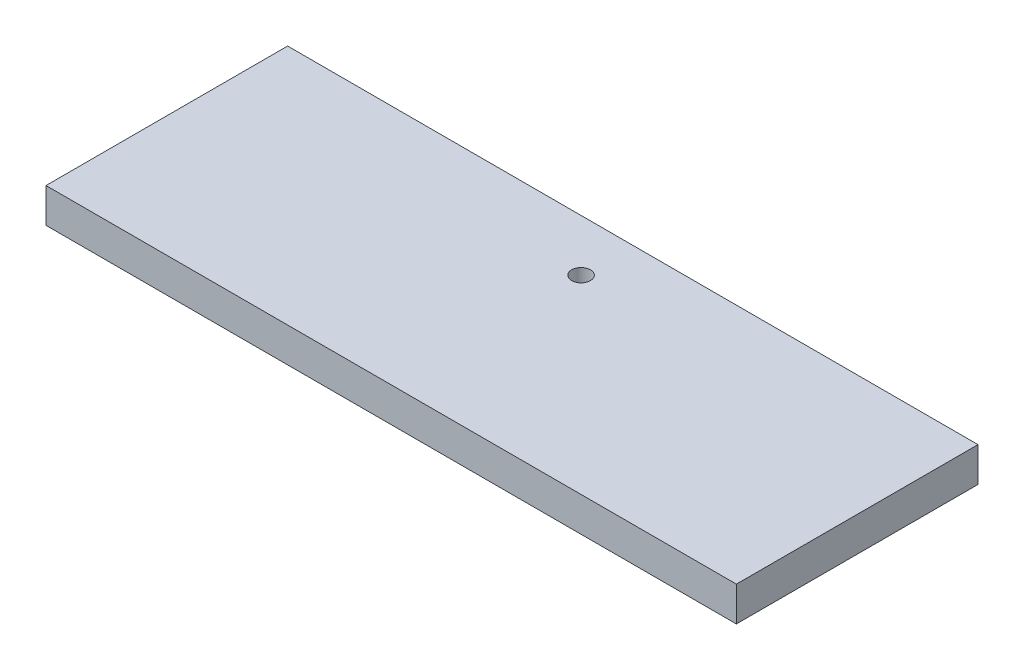
from build123d import *

# Parameters (mm, degrees)
SKETCH1_W                 = 127
SKETCH1_H                 = 44.45
BOSS_EXTRUDE1_DEPTH       = 6.35
F_8_32_TAPPED_HOLE1_D     = 3.4544
F_8_32_TAPPED_HOLE1_DEPTH = 12.446
F_8_32_TAPPED_HOLE1_TIP   = 1.037806461


with BuildPart() as part:
    # Sketch1 → Boss-Extrude1 (new body)
    with BuildSketch(Plane(origin=(0, 0, 0), x_dir=(1, 0, 0), z_dir=(0, 1, 0))):
        Rectangle(SKETCH1_W, SKETCH1_H)
    extrude(amount=BOSS_EXTRUDE1_DEPTH)

    # #8-32 Tapped Hole1
    with Locations(Plane(origin=(0, 6.35, -12.7), x_dir=(0, 0, 1), z_dir=(0, 1, 0))):
        with Locations((0, 0)):
            Hole(F_8_32_TAPPED_HOLE1_D / 2, depth=F_8_32_TAPPED_HOLE1_DEPTH)
            with Locations((0, 0, -(F_8_32_TAPPED_HOLE1_DEPTH + F_8_32_TAPPED_HOLE1_TIP / 2))):  # 118° drill point
                Cone(0, F_8_32_TAPPED_HOLE1_D / 2, F_8_32_TAPPED_HOLE1_TIP, mode=Mode.SUBTRACT)


solid = part.part
